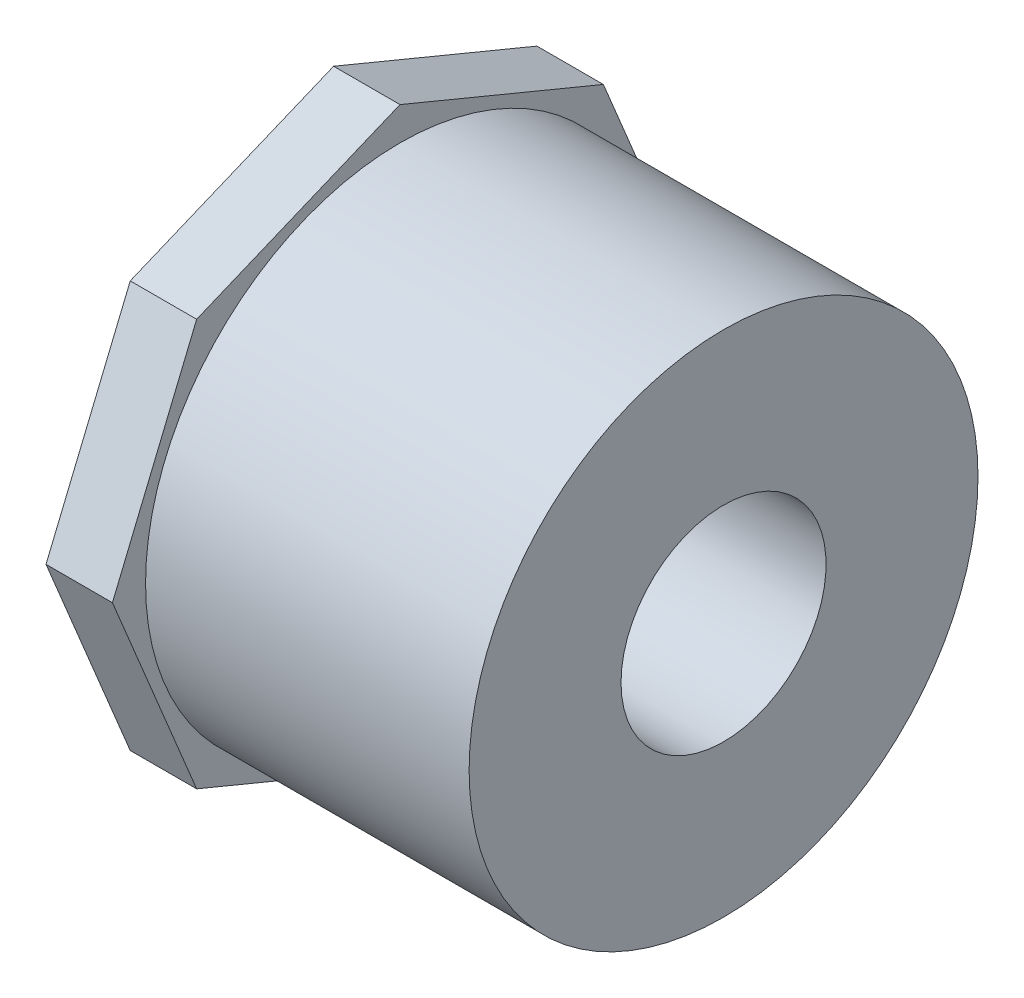
from build123d import *

# Parameters (mm, degrees)
SKETCH2_R           = 16.8275
BOSS_EXTRUDE1_DEPTH = 7.874


with BuildPart() as part:
    # Sketch1 → Revolve1 (revolve)
    with BuildSketch(Plane.XY):
        Polygon((-46.228, -30.1625), (0, -30.1625), (0, -12.1539), (-17.78, -12.1539), (-17.78, -16.637), (-46.228, -16.8275), align=None)
    revolve(axis=Axis((-46.228, 0, 0), (1, 0, 0)))

    # Sketch2 → Boss-Extrude1 (add)
    with BuildSketch(Plane.ZY.offset(46.228)):
        Polygon((0, 34.09102474), (-24.105994772, 24.105994772), (-34.09102474, 0), (-24.105994772, -24.105994772), (0, -34.09102474), (24.105994772, -24.105994772), (34.09102474, 0), (24.105994772, 24.105994772), align=None)
        Circle(SKETCH2_R, mode=Mode.SUBTRACT)
    extrude(amount=-BOSS_EXTRUDE1_DEPTH)


solid = part.part
